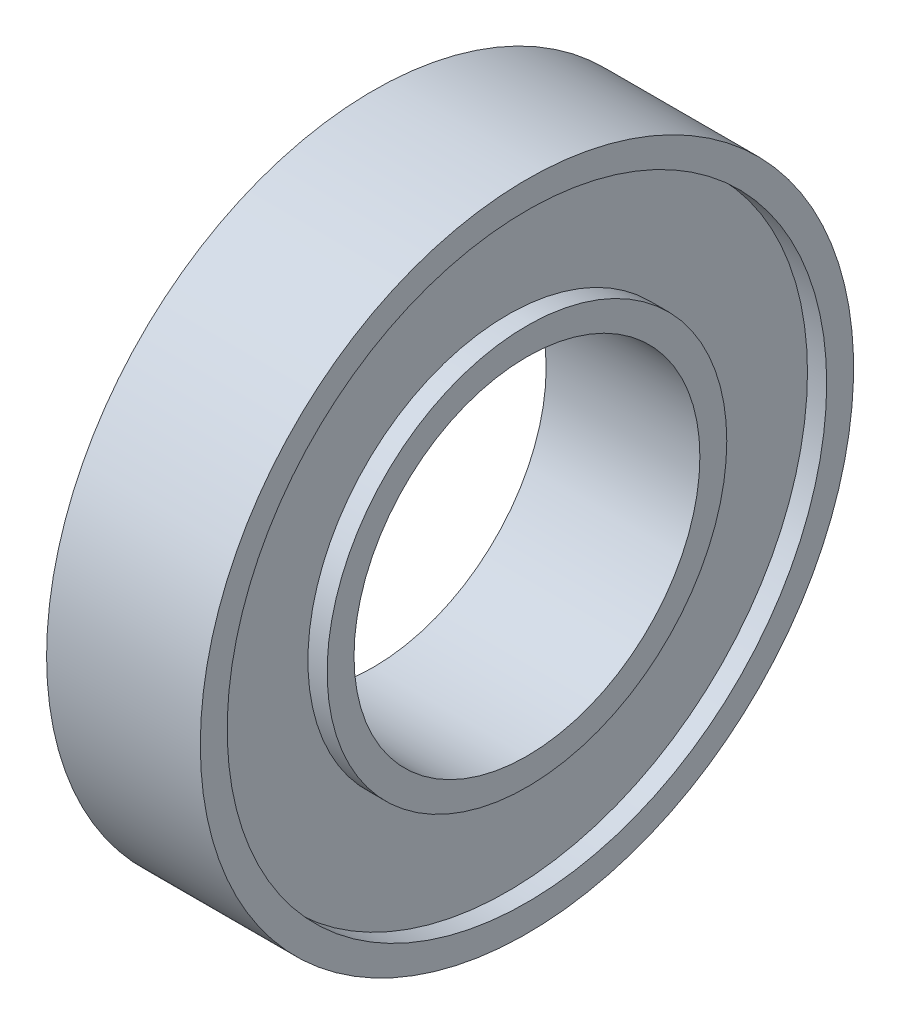
from build123d import *

# Parameters (mm, degrees)
CROQUIS1_W            = 4
CROQUIS1_H            = 4
CROQUIS2_R            = 7.8
CROQUIS2_R_2          = 5.2
CORTAR_EXTRUIR1_DEPTH = 0.5


with BuildPart() as part:
    # Croquis1 → Revolución1 (revolve)
    with BuildSketch(Plane.XY):
        with Locations((2, 6.5)):
            Rectangle(CROQUIS1_W, CROQUIS1_H)
    revolve(axis=Axis((0, 0, 0), (1, 0, 0)))

    # Croquis2 → Cortar-Extruir1 (cut)
    with BuildSketch(Plane(origin=(4, 0, 0), x_dir=(0, 0, -1), z_dir=(1, 0, 0))):
        Circle(CROQUIS2_R)
        Circle(CROQUIS2_R_2, mode=Mode.SUBTRACT)
    cortar_extruir1 = extrude(amount=-CORTAR_EXTRUIR1_DEPTH, mode=Mode.SUBTRACT)

    # Simetría1: Cortar-Extruir1 across plane
    add(cortar_extruir1.mirror(Plane(origin=(2, 0, 0), x_dir=(0, 0, 1), z_dir=(1, 0, 0))), mode=Mode.SUBTRACT)


solid = part.part
